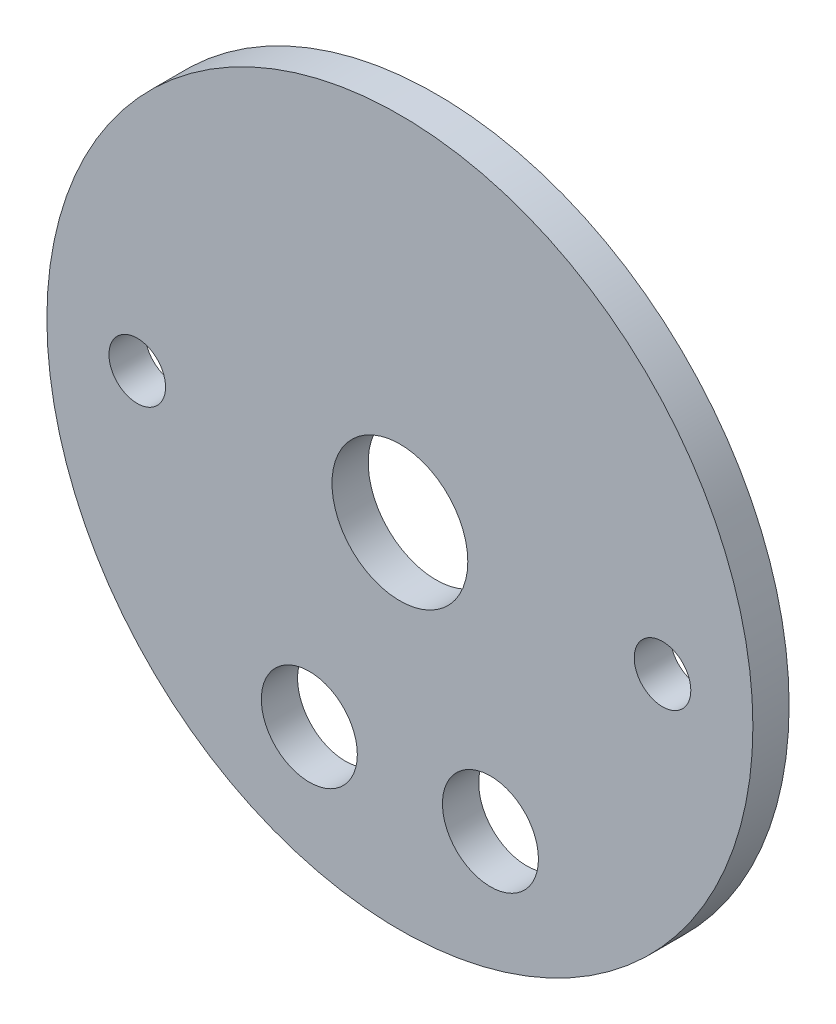
from build123d import *

# Parameters (mm, degrees)
SKETCH1_R           = 49.5046
BOSS_EXTRUDE1_DEPTH = 5.08
SKETCH2_R           = 47.625
BOSS_EXTRUDE2_DEPTH = 3.175
SKETCH3_R           = 6.731
SKETCH3_R_2         = 3.96875
SKETCH3_R_3         = 9.525
CUT_EXTRUDE1_DEPTH  = 9.255
SKETCH4_R           = 55.708104083
CUT_EXTRUDE2_DEPTH  = 3.175


with BuildPart() as part:
    # Sketch1 → Boss-Extrude1 (new body)
    with BuildSketch(Plane.XY):
        Circle(SKETCH1_R)
    extrude(amount=BOSS_EXTRUDE1_DEPTH)

    # Sketch2 → Boss-Extrude2 (add)
    with BuildSketch(Plane.XY.offset(5.08)):
        Circle(SKETCH2_R)
    extrude(amount=BOSS_EXTRUDE2_DEPTH)

    # Sketch3 → Cut-Extrude1 (cut, through all)
    with BuildSketch(Plane.XY.offset(8.255)):
        with Locations((-12.7, -31.166793627)):
            Circle(SKETCH3_R)
        with Locations((12.7, -31.166793627)):
            Circle(SKETCH3_R)
        with Locations((-36.83, 0)):
            Circle(SKETCH3_R_2)
        with Locations((36.83, 0)):
            Circle(SKETCH3_R_2)
        Circle(SKETCH3_R_3)
    extrude(amount=-CUT_EXTRUDE1_DEPTH, mode=Mode.SUBTRACT)

    # Sketch4 → Cut-Extrude2 (cut)
    with BuildSketch(Plane.XY.offset(8.255)):
        Circle(SKETCH4_R)
    extrude(amount=-CUT_EXTRUDE2_DEPTH, mode=Mode.SUBTRACT)


solid = part.part
